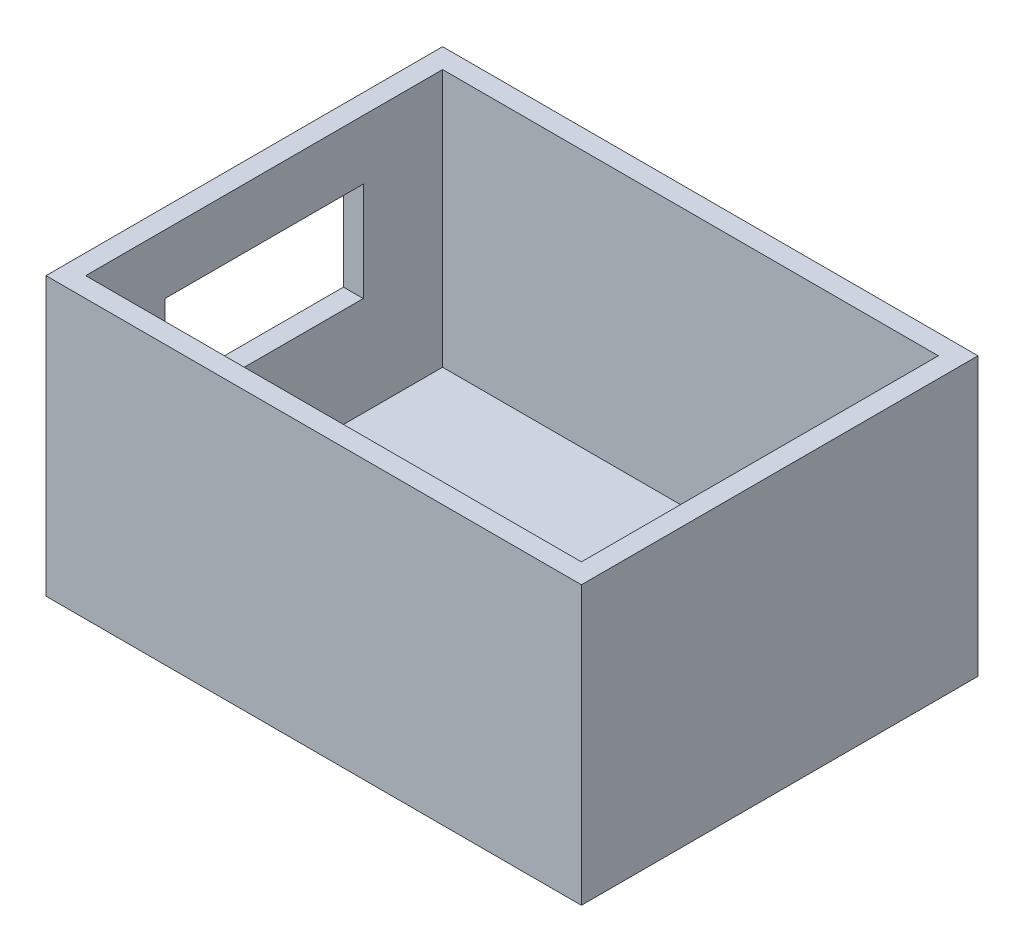
from build123d import *

# Parameters (mm, degrees)
CROQUIS1_W              = 27
CROQUIS1_H              = 20
CROQUIS1_W_2            = 25
CROQUIS1_H_2            = 18
SALIENTE_EXTRUIR1_DEPTH = 14
CROQUIS1_3_W            = 25
CROQUIS1_3_H            = 18
SALIENTE_EXTRUIR2_DEPTH = 1
CROQUIS2_W              = 10
CROQUIS2_H              = 5
CORTAR_EXTRUIR1_DEPTH   = 1


with BuildPart() as part:
    # Croquis1 → Saliente-Extruir1 (new body)
    with BuildSketch(Plane(origin=(0, 0, 0), x_dir=(1, 0, 0), z_dir=(0, 1, 0))):
        with Locations((12.5, 9)):
            Rectangle(CROQUIS1_W, CROQUIS1_H)
        with Locations((12.5, 9)):
            Rectangle(CROQUIS1_W_2, CROQUIS1_H_2, mode=Mode.SUBTRACT)
    extrude(amount=SALIENTE_EXTRUIR1_DEPTH)

    # Croquis1_3 → Saliente-Extruir2 (add)
    with BuildSketch(Plane(origin=(0, 0, 0), x_dir=(1, 0, 0), z_dir=(0, 1, 0))):
        with Locations((12.5, 9)):
            Rectangle(CROQUIS1_3_W, CROQUIS1_3_H)
    extrude(amount=SALIENTE_EXTRUIR2_DEPTH)

    # Croquis2 → Cortar-Extruir1 (cut)
    with BuildSketch(Plane.ZY.offset(1)):
        with Locations((-9, 8.5)):
            Rectangle(CROQUIS2_W, CROQUIS2_H)
    extrude(amount=-CORTAR_EXTRUIR1_DEPTH, mode=Mode.SUBTRACT)


solid = part.part
